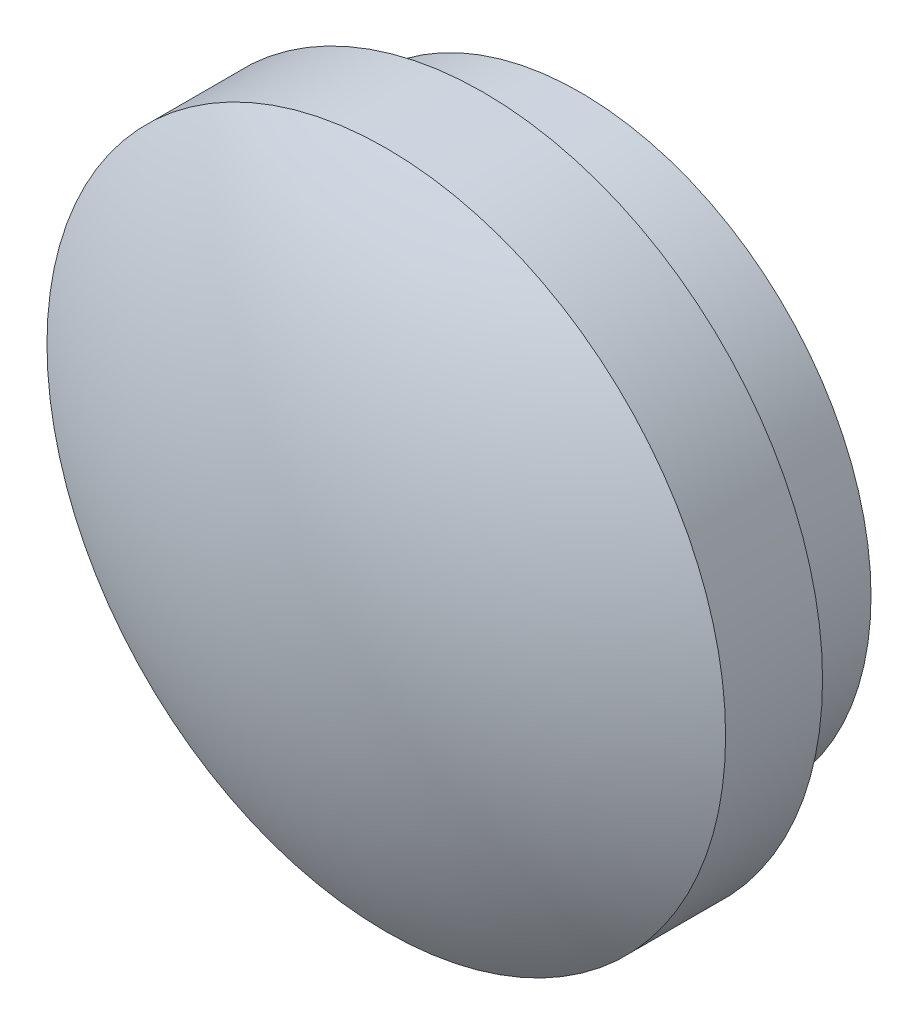
from build123d import *

# Parameters (mm, degrees)
SKETCH1_R         = 7.62
EXTRUDE1_DEPTH    = 2.54
SKETCH2_R         = 8.89
EXTRUDE2_DEPTH    = 2.54
DOME1_FACE_RADIUS = 8.89
DOME1_HEIGHT      = 2.54


with BuildPart() as part:
    # Sketch1 → Extrude1 (new body)
    with BuildSketch(Plane.XY):
        Circle(SKETCH1_R)
    extrude(amount=EXTRUDE1_DEPTH)

    # Sketch2 → Extrude2 (add)
    with BuildSketch(Plane.XY.offset(2.54)):
        Circle(SKETCH2_R)
    extrude(amount=EXTRUDE2_DEPTH)

    # Dome1: a dome of height H over a round flat face of radius A is a cap of a sphere of radius (A * A + H * H) / (2 * H)
    dome1_r = (DOME1_FACE_RADIUS * DOME1_FACE_RADIUS + DOME1_HEIGHT * DOME1_HEIGHT) / (2 * DOME1_HEIGHT)
    dome1_base = Plane((0, 0, 5.08), z_dir=(0, 0, 1))
    with Locations(dome1_base.offset(DOME1_HEIGHT - dome1_r)):
        dome1_ball = Sphere(dome1_r, mode=Mode.PRIVATE)
    add(split(dome1_ball, bisect_by=dome1_base, keep=Keep.TOP, mode=Mode.PRIVATE))


solid = part.part
